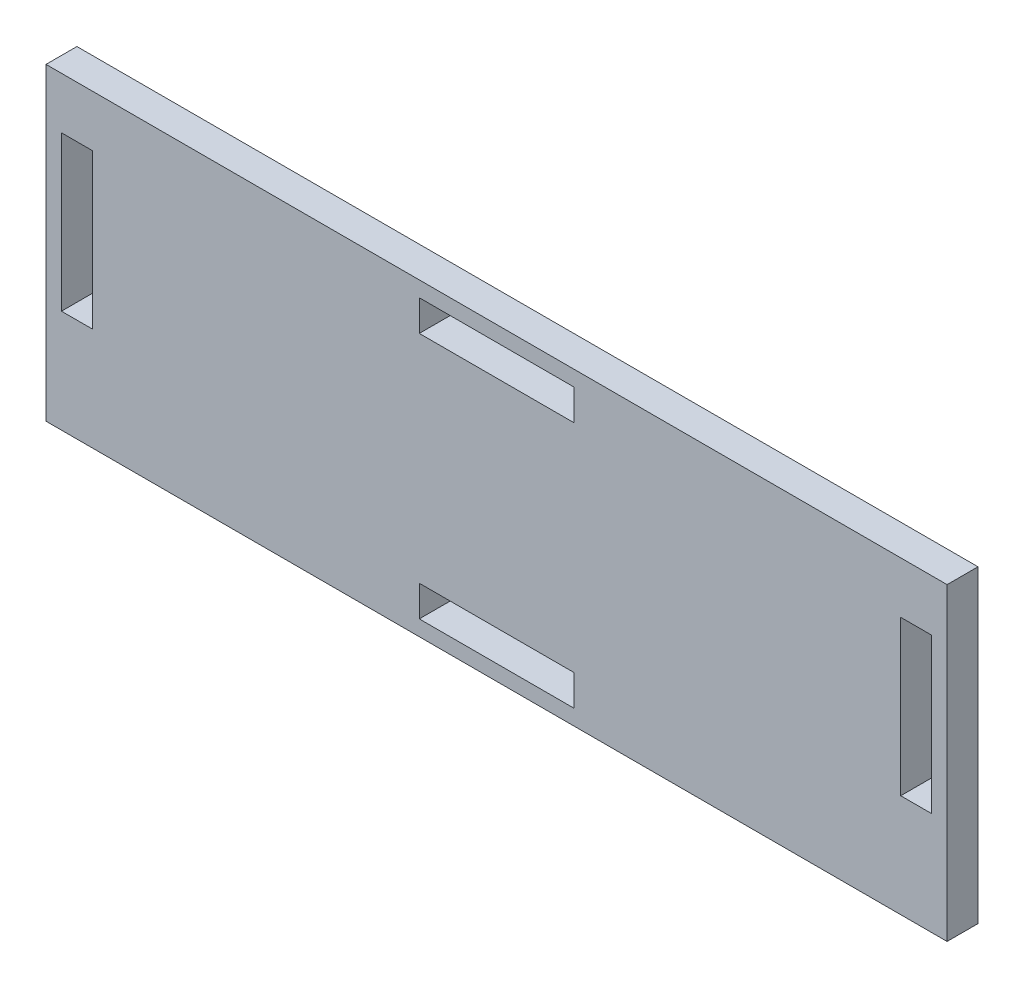
from build123d import *

# Parameters (mm, degrees)
SKETCH1_W           = 87.47
SKETCH1_H           = 30
BOSS_EXTRUDE1_DEPTH = 3
SKETCH2_W           = 15
SKETCH2_H           = 3
SKETCH2_W_2         = 3
SKETCH2_H_2         = 15
CUT_EXTRUDE1_DEPTH  = 3


with BuildPart() as part:
    # Sketch1 → Boss-Extrude1 (new body)
    with BuildSketch(Plane.XY):
        with Locations((43.735, 15)):
            Rectangle(SKETCH1_W, SKETCH1_H)
    extrude(amount=BOSS_EXTRUDE1_DEPTH)

    # Sketch2 → Cut-Extrude1 (cut)
    with BuildSketch(Plane.XY.offset(3)):
        with Locations((43.735, 27)):
            Rectangle(SKETCH2_W, SKETCH2_H)
        with Locations((43.735, 3)):
            Rectangle(SKETCH2_W, SKETCH2_H)
        with Locations((3, 17.5)):
            Rectangle(SKETCH2_W_2, SKETCH2_H_2)
        with Locations((84.47, 17.5)):
            Rectangle(SKETCH2_W_2, SKETCH2_H_2)
    extrude(amount=-CUT_EXTRUDE1_DEPTH, mode=Mode.SUBTRACT)


solid = part.part
